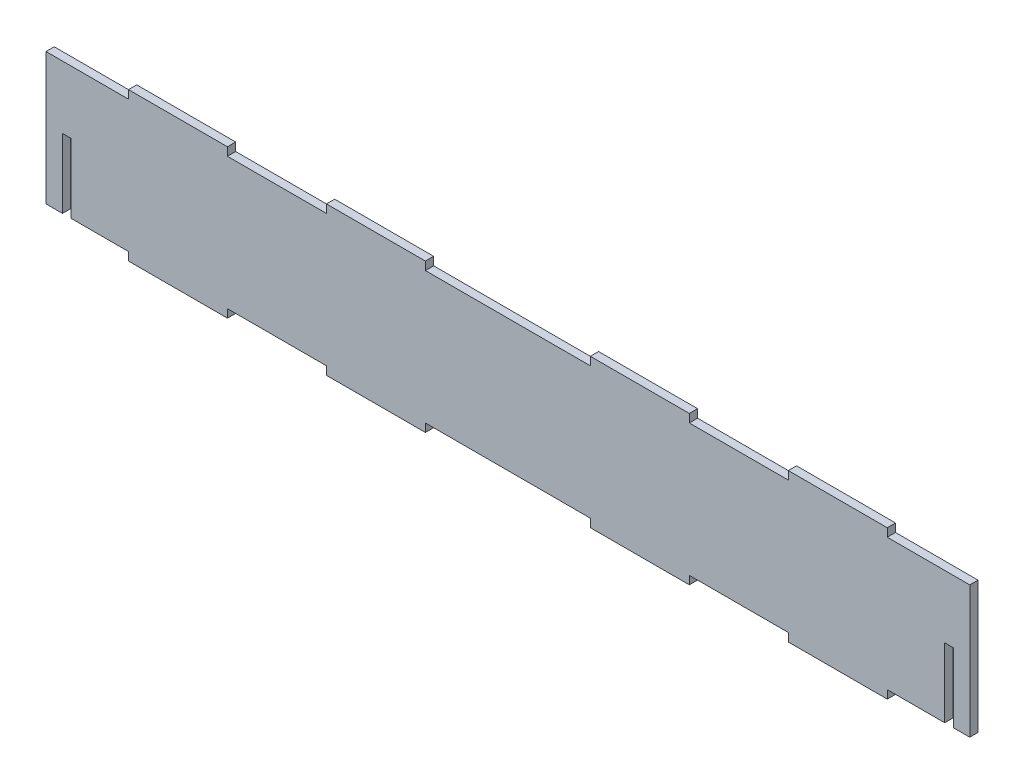
from build123d import *

# Parameters (mm, degrees)
SKETCH1_W               = 355.6
SKETCH1_H               = 50.8
BOSS_EXTRUDE1_DEPTH     = 3.175
SKETCH2_W               = 38.1
SKETCH2_H               = 3.175
BOSS_EXTRUDE2_DEPTH     = 3.175
MIRROR2_COPY_1_SKETCH_W = 38.1
MIRROR2_COPY_1_SKETCH_H = 3.175
MIRROR2_COPY_1_DEPTH    = 3.175
SKETCH3_W               = 3.302
SKETCH3_H               = 26.67
CUT_EXTRUDE1_DEPTH      = 3.175


with BuildPart() as part:
    # Sketch1 → Boss-Extrude1 (new body)
    with BuildSketch(Plane.XY):
        with Locations((177.8, 25.4)):
            Rectangle(SKETCH1_W, SKETCH1_H)
    extrude(amount=BOSS_EXTRUDE1_DEPTH)

    # Sketch2 → Boss-Extrude2 (add)
    with BuildSketch(Plane(origin=(0, 50.8, 0), x_dir=(1, 0, 0), z_dir=(0, 1, 0))):
        with Locations((50.8, -1.5875)):
            Rectangle(SKETCH2_W, SKETCH2_H)
        with Locations((127, -1.5875)):
            Rectangle(SKETCH2_W, SKETCH2_H)
    boss_extrude2 = extrude(amount=BOSS_EXTRUDE2_DEPTH)

    # Mirror1: Boss-Extrude2 across plane
    add(boss_extrude2.mirror(Plane.ZY.offset(-177.8)))

    # Mirror2: Boss-Extrude2 across plane
    add(boss_extrude2.mirror(Plane.ZX.offset(25.4)))

    # Mirror2 copy 1 sketch → Mirror2 copy 1 (add)
    with BuildSketch(Plane(origin=(355.6, 0, 0), x_dir=(-1, 0, 0), z_dir=(0, -1, 0))):
        with Locations((50.8, -1.5875)):
            Rectangle(MIRROR2_COPY_1_SKETCH_W, MIRROR2_COPY_1_SKETCH_H)
        with Locations((127, -1.5875)):
            Rectangle(MIRROR2_COPY_1_SKETCH_W, MIRROR2_COPY_1_SKETCH_H)
    extrude(amount=MIRROR2_COPY_1_DEPTH)

    # Sketch3 → Cut-Extrude1 (cut)
    with BuildSketch(Plane(origin=(0, 0, 0), x_dir=(-1, 0, 0), z_dir=(0, 0, -1))):
        with Locations((-8.001, 13.335)):
            Rectangle(SKETCH3_W, SKETCH3_H)
    cut_extrude1 = extrude(amount=-CUT_EXTRUDE1_DEPTH, mode=Mode.SUBTRACT)

    # Mirror3: Cut-Extrude1 across plane
    add(cut_extrude1.mirror(Plane.ZY.offset(-177.8)), mode=Mode.SUBTRACT)


solid = part.part
